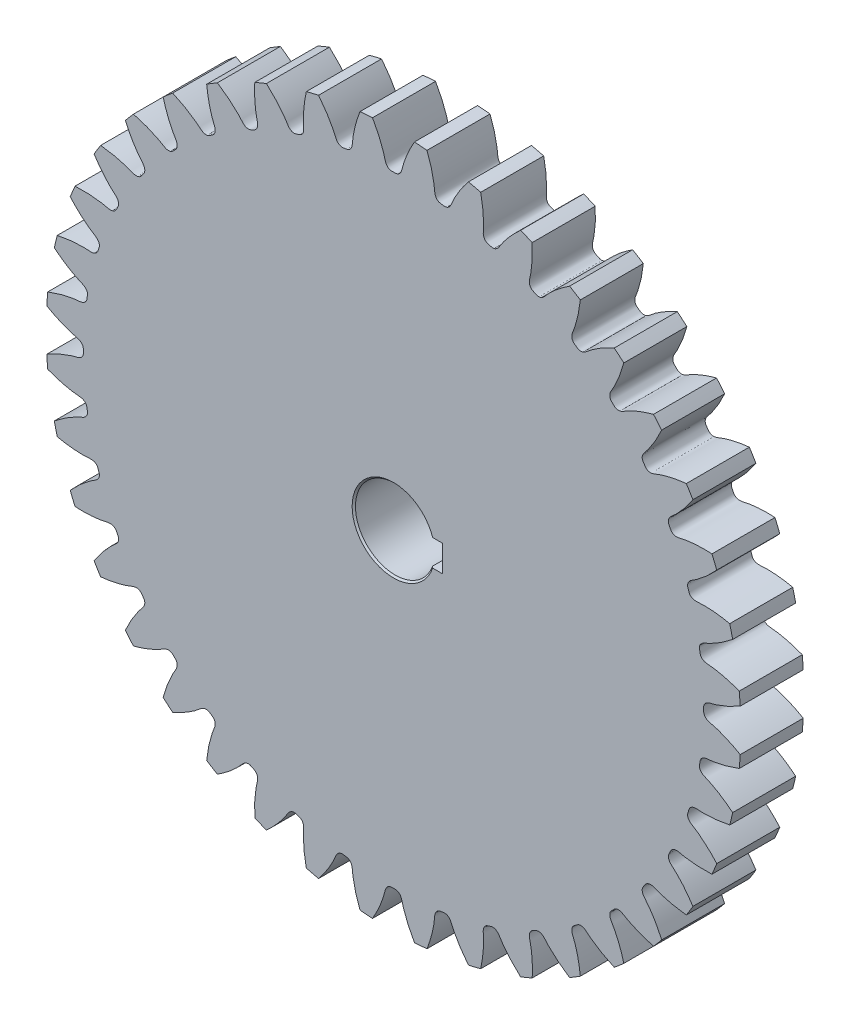
from build123d import *

# Parameters (mm, degrees)
SKETCHREVOLVEBANHRANGMAMXOAYGEAR_W       = 19.05
SKETCHREVOLVEBANHRANGMAMXOAYGEAR_H       = 104.999998423
TOOTHEXTRUDECUTBANHRANGMAMXOAYGEAR_DEPTH = 9.525
PATTERNBANHRANGMAMXOAYGEAR_COUNT         = 40
HUBSKETCHSIDE1_W                         = 20
HUBSKETCHSIDE1_H                         = 25
KEYWAY_DEPTH                             = 152.133399283
KEYWAY_DEPTH_BACK                        = 152.133399283
KEYWAYSKETCH_W                           = 6.999999895
KEYWAYSKETCH_H                           = 7.99999988


with BuildPart() as part:
    # SketchRevolvebanhrangmamxoayGear → banhrangmamxoayGear (revolve)
    with BuildSketch(Plane(origin=(0, 0, 0), x_dir=(0, 0, -1), z_dir=(1, 0, 0))):
        with Locations((0, 52.499999212)):
            Rectangle(SKETCHREVOLVEBANHRANGMAMXOAYGEAR_W, SKETCHREVOLVEBANHRANGMAMXOAYGEAR_H)
    revolve(axis=Axis((0, 0, 0), (0, 0, -1)))

    # SketchToothbanhrangmamxoayGear → ToothExtrudeCutbanhrangmamxoayGear (cut, symmetric)
    with BuildSketch(Plane.XY):
        with BuildLine():
            ThreePointArc((105.050233917, 6.481552376), (105.249998419, 0), (105.050233917, -6.481552376))
            add(Edge.make_bspline(
                [(105.050233917, -6.481552376), (104.583211614, -6.208643817), (103.888565538, -5.818470998), (102.966176981, -5.332771934), (102.307643875, -5.000789723), (101.669965618, -4.693377404), (101.053798264, -4.409686818), (100.459774256, -4.148854179), (99.888502141, -3.910000838), (99.340566031, -3.69223426), (98.816526049, -3.494646969), (98.316915416, -3.316322854), (97.842249155, -3.15631812), (97.392993052, -3.013729128), (96.969668149, -2.887464138), (96.572496041, -2.777018316), (96.020449267, -2.632037413), (95.515459379, -2.527192851), (95.079479231, -2.358323267), (94.857097585, -2.253325436), (94.633699822, -2.12239027), (94.405261612, -1.952408753), (94.172562604, -1.722435861), (93.951120172, -1.406382676), (93.792869802, -1.008003612), (93.731301502, -0.522986058), (93.76049971, 0), (93.731301502, 0.522986058), (93.792869802, 1.008003612), (93.951120172, 1.406382676), (94.172562604, 1.722435861), (94.405261612, 1.952408753), (94.633699822, 2.12239027), (94.857097585, 2.253325436), (95.079479231, 2.358323267), (95.515459379, 2.527192851), (96.020449267, 2.632037413), (96.572496041, 2.777018316), (96.969668149, 2.887464138), (97.392993052, 3.013729128), (97.842249155, 3.15631812), (98.316915416, 3.316322854), (98.816526049, 3.494646969), (99.340566031, 3.69223426), (99.888502141, 3.910000838), (100.459774256, 4.148854179), (101.053798264, 4.409686818), (101.669965618, 4.693377404), (102.307643875, 5.000789723), (102.966176981, 5.332771934), (103.888565538, 5.818470998), (104.583211614, 6.208643817), (105.050233917, 6.481552376)],
                knots=[0, 0, 0, 0, 0.058973182, 0.086847836, 0.113647867, 0.139373272, 0.164024054, 0.187600211, 0.210101744, 0.231528652, 0.251880937, 0.271158597, 0.289361632, 0.306490043, 0.32254383, 0.337522993, 0.351427531, 0.384797092, 0.393515373, 0.402340396, 0.411584695, 0.421700984, 0.433308518, 0.447108493, 0.463489664, 0.47949417, 0.5, 0.52050583, 0.536510336, 0.552891507, 0.566691482, 0.578299016, 0.588415305, 0.597659604, 0.606484627, 0.615202908, 0.648572469, 0.662477007, 0.67745617, 0.693509957, 0.710638368, 0.728841403, 0.748119063, 0.768471348, 0.789898256, 0.812399789, 0.835975946, 0.860626728, 0.886352133, 0.913152164, 0.941026818, 1, 1, 1, 1], degree=3))
        make_face()
    toothextrudecutbanhrangmamxoaygear = extrude(amount=TOOTHEXTRUDECUTBANHRANGMAMXOAYGEAR_DEPTH, both=True, mode=Mode.SUBTRACT)

    # PatternbanhrangmamxoayGear: ToothExtrudeCutbanhrangmamxoayGear ×40 about axis
    patternbanhrangmamxoaygear_axis = Axis((0, 0, 55), (0, 0, -1))
    for i in range(1, PATTERNBANHRANGMAMXOAYGEAR_COUNT):
        add(toothextrudecutbanhrangmamxoaygear.rotate(patternbanhrangmamxoaygear_axis, i * 360 / PATTERNBANHRANGMAMXOAYGEAR_COUNT), mode=Mode.SUBTRACT)

    # HubSketchSide1 → HubRevolve1 (revolve)
    with BuildSketch(Plane(origin=(0, 0, 0), x_dir=(0, 0, -1), z_dir=(1, 0, 0))):
        with Locations((19.525, 12.5)):
            Rectangle(HUBSKETCHSIDE1_W, HUBSKETCHSIDE1_H)
    revolve(axis=Axis((0, 0, 0), (0, 0, -1)))

    # BoreRevolveSketch → BoreRevolveCut (revolve, cut)
    with BuildSketch(Plane(origin=(0, 0, 0), x_dir=(0, 0, -1), z_dir=(1, 0, 0))):
        Polygon((-9.525, 0), (29.525, 0), (29.525, 12.5), (29.025, 12), (-9.025, 12), (-9.525, 12.5), align=None)
    revolve(axis=Axis((0, 0, 0), (0, 0, -1)), mode=Mode.SUBTRACT)

    # KeywaySketch → Keyway (cut, two sides: drawn at the far end of the back side and taken through both)
    with BuildSketch(Plane.XY.offset(-KEYWAY_DEPTH_BACK)):
        with Locations((11.313708521, 0)):
            Rectangle(KEYWAYSKETCH_W, KEYWAYSKETCH_H)
    extrude(amount=KEYWAY_DEPTH + KEYWAY_DEPTH_BACK, mode=Mode.SUBTRACT)


solid = part.part
